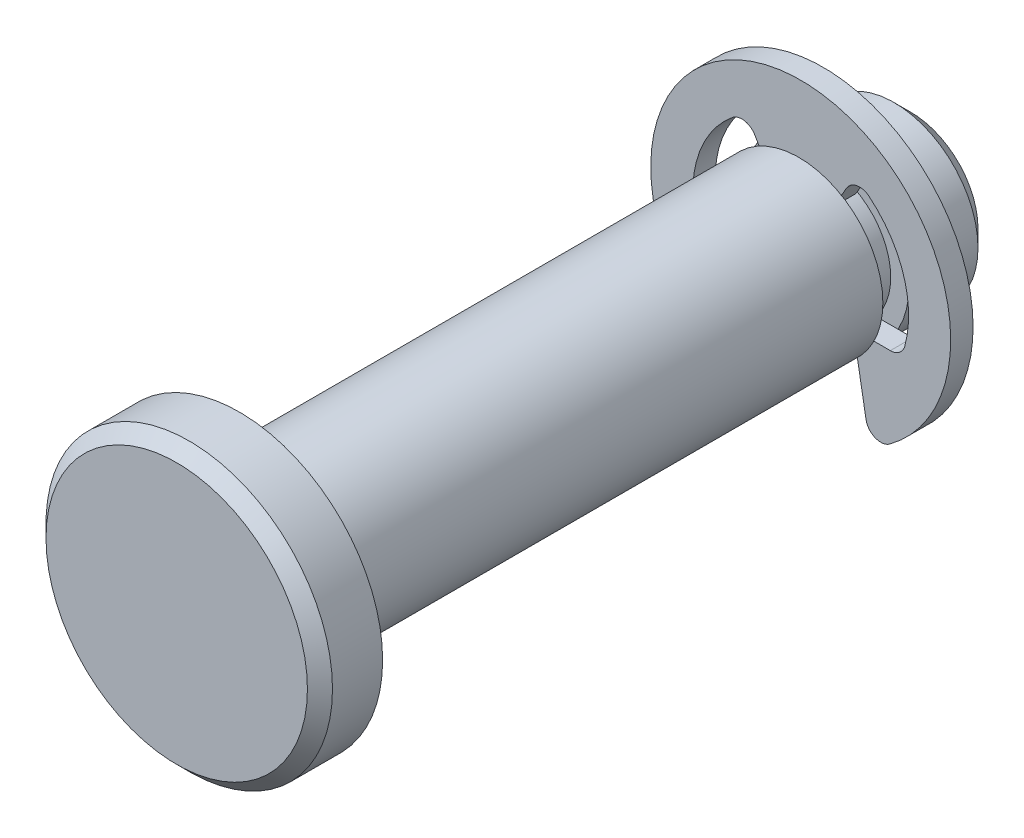
from build123d import *

# Parameters (mm, degrees)
SKETCH2_R      = 2.38125
EXTRUDE1_DEPTH = 9.525
SKETCH3_W      = 0.7366
SKETCH3_H      = 0.51435
SKETCH8_R      = 4.064
EXTRUDE6_DEPTH = 1.778
CHAMFER2_SIZE  = 0.3556
SKETCH4_R      = 4.2545
SKETCH4_R_2    = 1.8669
EXTRUDE2_DEPTH = 0.3175
EXTRUDE4_DEPTH = 10.525
EXTRUDE5_DEPTH = 0.635
FILLET1_R      = 0.42545
CHAMFER1_SIZE  = 0.47625


with BuildPart() as part:
    # Sketch2 → Extrude1 (new body, symmetric)
    with BuildSketch(Plane.XY):
        Circle(SKETCH2_R)
    extrude(amount=EXTRUDE1_DEPTH, both=True)

    # Sketch3 → Cut-Revolve1 (revolve, cut)
    with BuildSketch(Plane(origin=(0, 0, 0), x_dir=(0, 0, -1), z_dir=(1, 0, 0))):
        with Locations((6.7183, 2.124075)):
            Rectangle(SKETCH3_W, SKETCH3_H)
    revolve(axis=Axis((0, 0, 9.525), (0, 0, -1)), mode=Mode.SUBTRACT)

    # Sketch8 → Extrude6 (add)
    with BuildSketch(Plane.XY.offset(9.525)):
        Circle(SKETCH8_R)
    extrude(amount=EXTRUDE6_DEPTH)

    # Chamfer2
    chamfer2_edges = [part.edges().sort_by_distance(p)[0] for p in [
        (-4.064, 0, 11.303),
    ]]
    chamfer(chamfer2_edges, length=CHAMFER2_SIZE)

    # Chamfer1
    chamfer1_edges = [part.edges().sort_by_distance(p)[0] for p in [
        (-2.38125, 0, -9.525),
    ]]
    chamfer(chamfer1_edges, length=CHAMFER1_SIZE)


with BuildPart() as body_2:
    # Sketch4 → Extrude2 (new body, symmetric)
    with BuildSketch(Plane.XY.offset(-6.7183)):
        Circle(SKETCH4_R)
        Circle(SKETCH4_R_2, mode=Mode.SUBTRACT)
    extrude(amount=EXTRUDE2_DEPTH, both=True)

    # Sketch5 → Extrude4 (cut, through all)
    with BuildSketch(Plane.XY):
        with BuildLine():
            Line((-1.53035, 2.650643953), (0, 0))
            Line((0, 0), (1.53035, 2.650643953))
            ThreePointArc((1.53035, 2.650643953), (2.889287878, 1.00990101), (2.84836284, -1.12014))
            Line((2.84836284, -1.12014), (1.49352, -1.12014))
            Line((1.49352, -1.12014), (1.96168838, -3.775254819))
            ThreePointArc((1.96168838, -3.775254819), (0, -4.2545), (-1.96168838, -3.775254819))
            Line((-1.96168838, -3.775254819), (-1.49352, -1.12014))
            Line((-1.49352, -1.12014), (-2.84836284, -1.12014))
            ThreePointArc((-2.84836284, -1.12014), (-2.889287878, 1.00990101), (-1.53035, 2.650643953))
        make_face()
    extrude(amount=-EXTRUDE4_DEPTH, mode=Mode.SUBTRACT)

    # Sketch6 → Extrude5 (add)
    with BuildSketch(Plane.XY.offset(-6.4008)):
        with BuildLine():
            Line((-0.93345, 1.616782826), (0.93345, 1.616782826))
            ThreePointArc((0.93345, 1.616782826), (0, 1.8669), (-0.93345, 1.616782826))
        make_face()
    extrude(amount=-EXTRUDE5_DEPTH)

    # Fillet1
    fillet1_edges = [body_2.edges().sort_by_distance(p)[0] for p in [
        (1.53035, 2.650643953, -6.7183),
        (1.96168838, -3.775254819, -6.7183),
        (-2.84836284, -1.12014, -6.7183),
        (2.84836284, -1.12014, -6.7183),
        (-1.96168838, -3.775254819, -6.7183),
        (-1.53035, 2.650643953, -6.7183),
    ]]
    fillet(fillet1_edges, radius=FILLET1_R)


solid = Compound([part.part, body_2.part])
